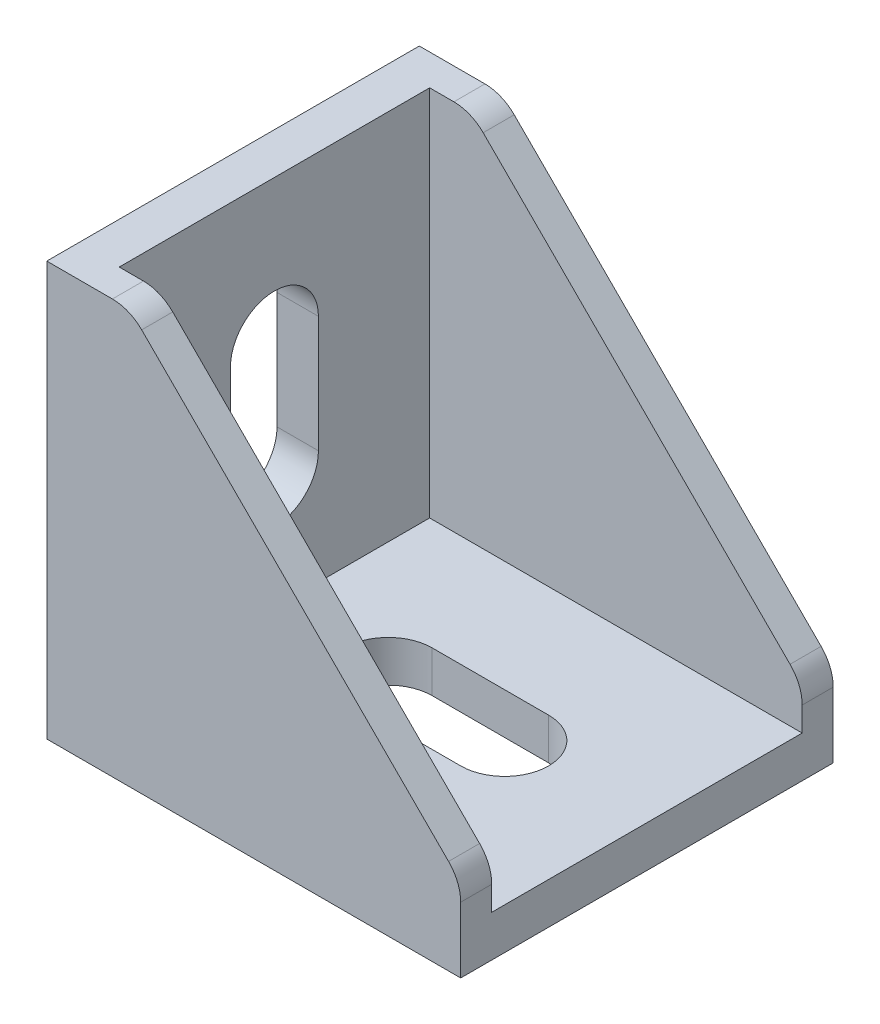
from build123d import *

# Parameters (mm, degrees)
EXTRUDE_1_DEPTH        = 18
EXTRUDE_2_DEPTH        = 3
FILLET_1_R             = 4
FILLET_1_OF_MIRROR_2_R = 4
CUT_EXTRUDE_1_DEPTH    = 5
SKETCH_4_W             = 2.5
SKETCH_4_H             = 7.8
EXTRUDE_3_DEPTH        = 2.5


with BuildPart() as part:
    # Эскиз1 → Бобышка-Вытянуть1 (new body, symmetric)
    with BuildSketch(Plane.XY):
        Polygon((0, 40), (0, 0), (40, 0), (40, 4), (4, 4), (4, 40), align=None)
    extrude(amount=EXTRUDE_1_DEPTH, both=True)

    # Эскиз2 → Бобышка-Вытянуть2 (add)
    with BuildSketch(Plane.XY.offset(18)):
        Polygon((40, 4), (4, 4), (4, 40), (8, 40), (40, 8), align=None)
    extrude_2 = extrude(amount=-EXTRUDE_2_DEPTH)

    # Скругление1
    fillet_1_edges = [part.edges().sort_by_distance(p)[0] for p in [
        (8, 40, 16.5),
        (40, 8, 16.5),
    ]]
    fillet(fillet_1_edges, radius=FILLET_1_R)

    # Зеркальное отражение2: Бобышка-Вытянуть2 across plane
    add(extrude_2.mirror(Plane.XY))

    # Скругление1 of Зеркальное отражение2
    fillet_1_of_mirror_2_edges = [part.edges().sort_by_distance(p)[0] for p in [
        (8, 40, -16.5),
        (40, 8, -16.5),
    ]]
    fillet(fillet_1_of_mirror_2_edges, radius=FILLET_1_OF_MIRROR_2_R)

    # Эскиз3 → Вырез-Вытянуть1 (cut, through all)
    with BuildSketch(Plane(origin=(0, 4, 0), x_dir=(1, 0, 0), z_dir=(0, 1, 0))):
        with BuildLine():
            Line((15, 4.25), (26.25, 4.25))
            ThreePointArc((26.25, 4.25), (30.5, 0), (26.25, -4.25))
            Line((26.25, -4.25), (15, -4.25))
            ThreePointArc((15, -4.25), (10.75, 0), (15, 4.25))
        make_face()
    cut_extrude_1 = extrude(amount=-CUT_EXTRUDE_1_DEPTH, mode=Mode.SUBTRACT)

    # Эскиз4 → Бобышка-Вытянуть3 (add)
    with BuildSketch(Plane.XZ):
        with Locations((4.25, 0)):
            Rectangle(SKETCH_4_W, SKETCH_4_H)
        with Locations((35.75, 0)):
            Rectangle(SKETCH_4_W, SKETCH_4_H)
    extrude_3 = extrude(amount=EXTRUDE_3_DEPTH)

    # Зеркальное отражение3: Вырез-Вытянуть1, Бобышка-Вытянуть3 across plane
    add(cut_extrude_1.mirror(Plane(origin=(0, 0, 0), x_dir=(0, 0, 1), z_dir=(-0.707106781, 0.707106781, 0))), mode=Mode.SUBTRACT)
    add(extrude_3.mirror(Plane(origin=(0, 0, 0), x_dir=(0, 0, 1), z_dir=(-0.707106781, 0.707106781, 0))))


solid = part.part
